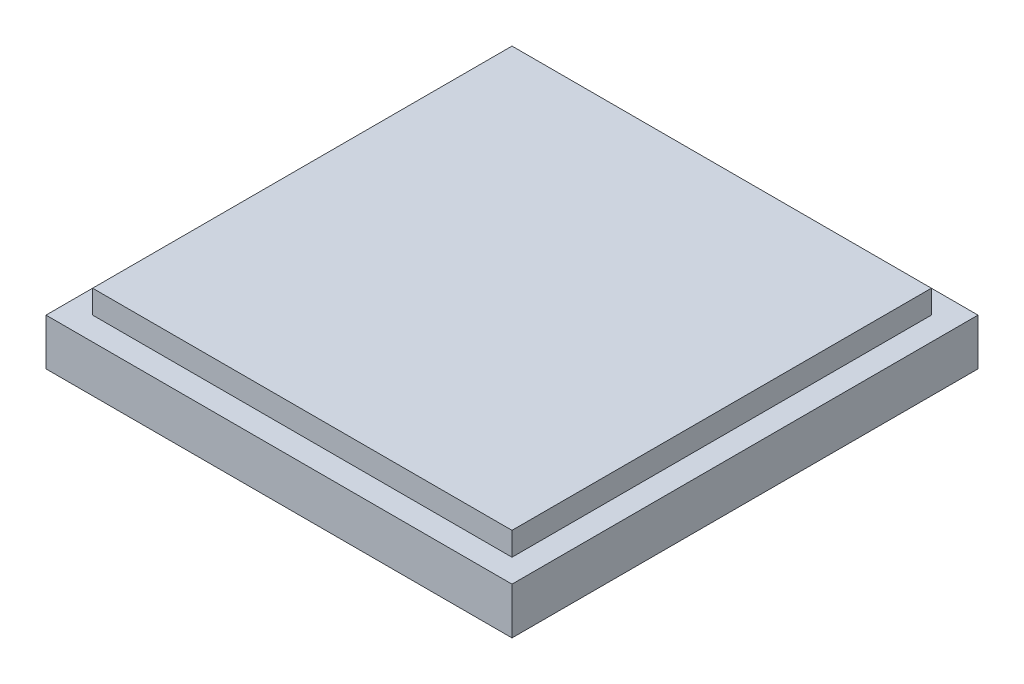
from build123d import *

# Parameters (mm, degrees)
CROQUIS1_W              = 50
CROQUIS1_H              = 50
SALIENTE_EXTRUIR1_DEPTH = 5
CROQUIS2_W              = 45
CROQUIS2_H              = 45
SALIENTE_EXTRUIR2_DEPTH = 2.5


with BuildPart() as part:
    # Croquis1 → Saliente-Extruir1 (new body)
    with BuildSketch(Plane(origin=(0, 0, 0), x_dir=(1, 0, 0), z_dir=(0, 1, 0))):
        Rectangle(CROQUIS1_W, CROQUIS1_H)
    extrude(amount=SALIENTE_EXTRUIR1_DEPTH)

    # Croquis2 → Saliente-Extruir2 (add)
    with BuildSketch(Plane(origin=(0, 5, 0), x_dir=(1, 0, 0), z_dir=(0, 1, 0))):
        Rectangle(CROQUIS2_W, CROQUIS2_H)
    extrude(amount=SALIENTE_EXTRUIR2_DEPTH)


solid = part.part
